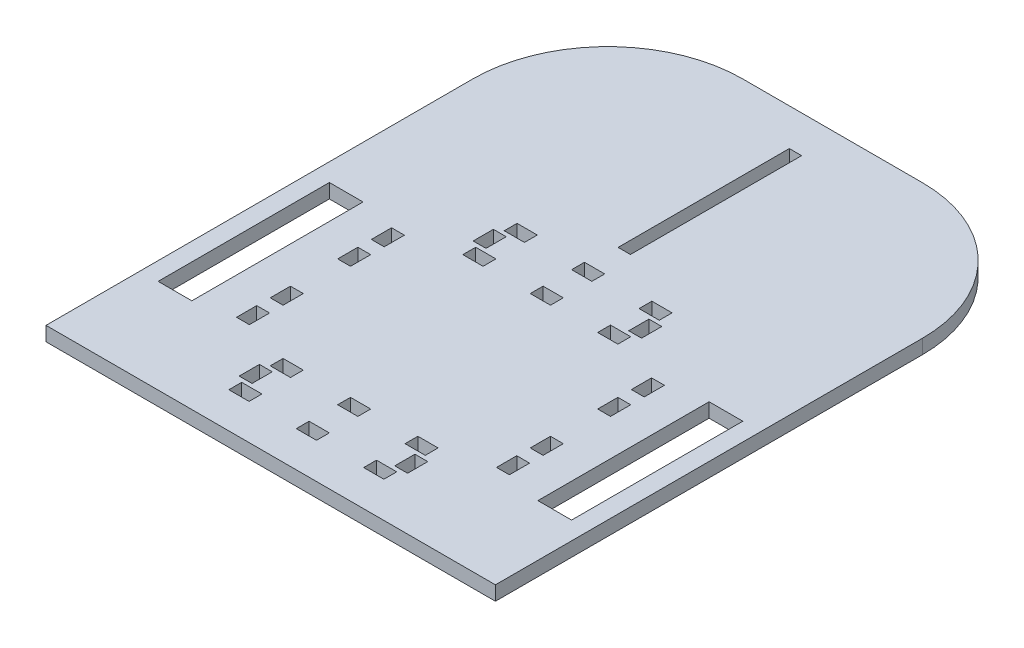
from build123d import *

# Parameters (mm, degrees)
SKETCH1_W           = 200
SKETCH1_H           = 250
SKETCH1_W_2         = 5.4862609
SKETCH1_H_2         = 76.2
SKETCH1_W_3         = 5.715
SKETCH1_H_3         = 9
SKETCH1_W_4         = 9
SKETCH1_H_4         = 5.715
SKETCH1_W_5         = 15
BOSS_EXTRUDE1_DEPTH = 6.35
FILLET1_R           = 60


with BuildPart() as part:
    # Sketch1 → Boss-Extrude1 (new body)
    with BuildSketch(Plane(origin=(0, 0, 0), x_dir=(1, 0, 0), z_dir=(0, 1, 0))):
        Rectangle(SKETCH1_W, SKETCH1_H)
        with Locations((0, 70.435892683)):
            Rectangle(SKETCH1_W_2, SKETCH1_H_2, mode=Mode.SUBTRACT)
        with Locations((57.8575, -60)):
            Rectangle(SKETCH1_W_3, SKETCH1_H_3, mode=Mode.SUBTRACT)
        with Locations((57.8575, -30)):
            Rectangle(SKETCH1_W_3, SKETCH1_H_3, mode=Mode.SUBTRACT)
        with Locations((0, -87.8575)):
            Rectangle(SKETCH1_W_4, SKETCH1_H_4, mode=Mode.SUBTRACT)
        with Locations((-57.8575, -60)):
            Rectangle(SKETCH1_W_3, SKETCH1_H_3, mode=Mode.SUBTRACT)
        with Locations((-57.8575, -30)):
            Rectangle(SKETCH1_W_3, SKETCH1_H_3, mode=Mode.SUBTRACT)
        with Locations((30, -87.8575)):
            Rectangle(SKETCH1_W_4, SKETCH1_H_4, mode=Mode.SUBTRACT)
        with Locations((-84.5, -45)):
            Rectangle(SKETCH1_W_5, SKETCH1_H_2, mode=Mode.SUBTRACT)
        with Locations((-30, -87.8575)):
            Rectangle(SKETCH1_W_4, SKETCH1_H_4, mode=Mode.SUBTRACT)
        with Locations((30, -106.2725)):
            Rectangle(SKETCH1_W_4, SKETCH1_H_4, mode=Mode.SUBTRACT)
        with Locations((0, -106.2725)):
            Rectangle(SKETCH1_W_4, SKETCH1_H_4, mode=Mode.SUBTRACT)
        with Locations((-30, -106.2725)):
            Rectangle(SKETCH1_W_4, SKETCH1_H_4, mode=Mode.SUBTRACT)
        with Locations((0, -2.1425)):
            Rectangle(SKETCH1_W_4, SKETCH1_H_4, mode=Mode.SUBTRACT)
        with Locations((30, -2.1425)):
            Rectangle(SKETCH1_W_4, SKETCH1_H_4, mode=Mode.SUBTRACT)
        with Locations((30, 16.2725)):
            Rectangle(SKETCH1_W_4, SKETCH1_H_4, mode=Mode.SUBTRACT)
        with Locations((0, 16.2725)):
            Rectangle(SKETCH1_W_4, SKETCH1_H_4, mode=Mode.SUBTRACT)
        with Locations((-30, 16.2725)):
            Rectangle(SKETCH1_W_4, SKETCH1_H_4, mode=Mode.SUBTRACT)
        with Locations((-30, -2.1425)):
            Rectangle(SKETCH1_W_4, SKETCH1_H_4, mode=Mode.SUBTRACT)
        with Locations((84.5, -45)):
            Rectangle(SKETCH1_W_5, SKETCH1_H_2, mode=Mode.SUBTRACT)
        with Locations((57.8575, -75)):
            Rectangle(SKETCH1_W_3, SKETCH1_H_3, mode=Mode.SUBTRACT)
        with Locations((-57.8575, -75)):
            Rectangle(SKETCH1_W_3, SKETCH1_H_3, mode=Mode.SUBTRACT)
        with Locations((57.8575, -15)):
            Rectangle(SKETCH1_W_3, SKETCH1_H_3, mode=Mode.SUBTRACT)
        with Locations((-57.8575, -15)):
            Rectangle(SKETCH1_W_3, SKETCH1_H_3, mode=Mode.SUBTRACT)
        with Locations((34.6075, -97.065)):
            Rectangle(SKETCH1_W_3, SKETCH1_H_3, mode=Mode.SUBTRACT)
        with Locations((-34.6075, -97.065)):
            Rectangle(SKETCH1_W_3, SKETCH1_H_3, mode=Mode.SUBTRACT)
        with Locations((34.6075, 7.065)):
            Rectangle(SKETCH1_W_3, SKETCH1_H_3, mode=Mode.SUBTRACT)
        with Locations((-34.6075, 7.065)):
            Rectangle(SKETCH1_W_3, SKETCH1_H_3, mode=Mode.SUBTRACT)
    extrude(amount=BOSS_EXTRUDE1_DEPTH)

    # Fillet1
    fillet1_edges = [part.edges().sort_by_distance(p)[0] for p in [
        (-100, 3.175, -125),
        (100, 3.175, -125),
    ]]
    fillet(fillet1_edges, radius=FILLET1_R)


solid = part.part
